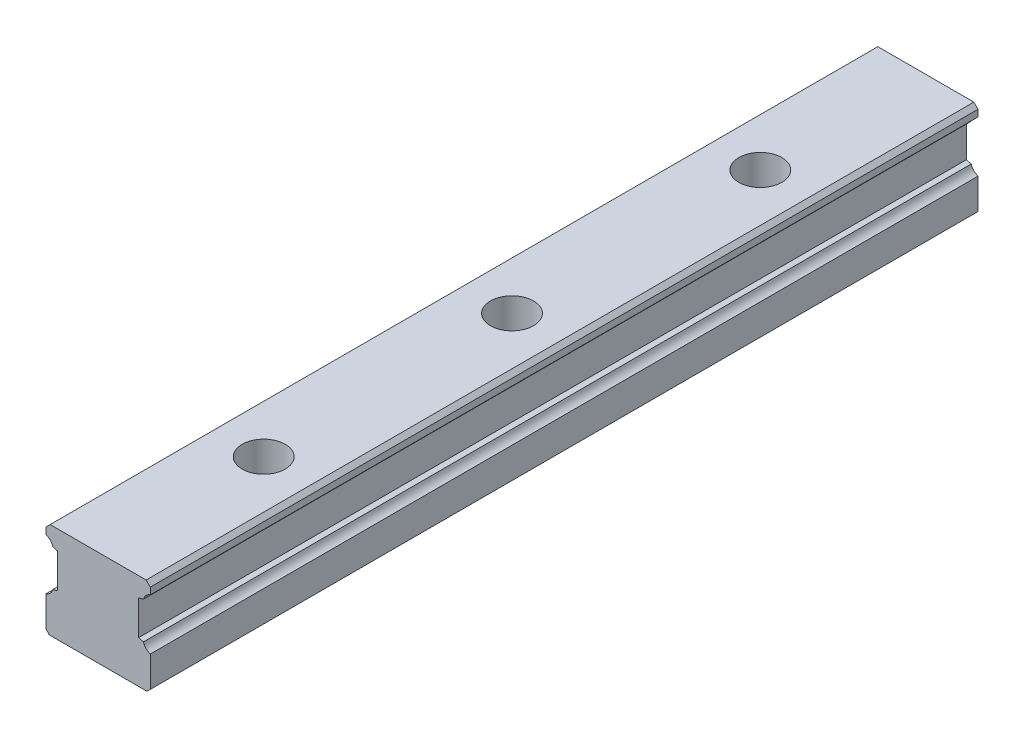
from build123d import *

# Parameters (mm, degrees)
RESSALTO_EXTRUS_O1_DEPTH                             = 500
REBAIXO_PARA_PARAFUSO_DE_CABE_A_SEXTAVAD_D           = 18
REBAIXO_PARA_PARAFUSO_DE_CABE_A_SEXTAVAD_DEPTH       = 58
REBAIXO_PARA_PARAFUSO_DE_CABE_A_SEXTAVAD_CBORE_D     = 26
REBAIXO_PARA_PARAFUSO_DE_CABE_A_SEXTAVAD_CBORE_DEPTH = 25
CHANFRO1_SIZE2                                       = 2.500287455
CHANFRO1_SIZE                                        = 2.500257245
CHANFRO2_SIZE2                                       = 2.500423779
CHANFRO2_SIZE                                        = 2.500287455
CHANFRO3_SIZE                                        = 2


with BuildPart() as part:
    # Esboço1 → Ressalto-extrusão1 (new body)
    with BuildSketch(Plane.XY):
        with BuildLine():
            Line((-31.5, 20.527298986), (-31.5, 0))
            Line((-31.5, 0), (31.5, 0))
            Line((31.5, 0), (31.5, 20.527298986))
            ThreePointArc((31.5, 20.527298986), (28.900076881, 22.150342104), (27.397266061, 24.82156445))
            Line((27.397266061, 24.82156445), (24.5, 25.597882749))
            Line((24.5, 25.597882749), (24.5, 46.397686197))
            Line((24.5, 46.397686197), (27.397119712, 47.17387922))
            ThreePointArc((27.397119712, 47.17387922), (28.898613337, 49.848990738), (31.5, 51.474872705))
            Line((31.5, 51.474872705), (31.5, 58))
            Line((31.5, 58), (-31.5, 58))
            Line((-31.5, 58), (-31.5, 51.474872705))
            ThreePointArc((-31.5, 51.474872705), (-28.899411057, 49.849685923), (-27.397802135, 47.175837466))
            Line((-27.397802135, 47.175837466), (-24.5, 46.399706372))
            Line((-24.5, 46.399706372), (-24.5, 25.596973237))
            Line((-24.5, 25.596973237), (-27.397939574, 24.823365186))
            ThreePointArc((-27.397939574, 24.823365186), (-28.900095464, 22.151244343), (-31.5, 20.527298986))
        make_face()
    extrude(amount=RESSALTO_EXTRUS_O1_DEPTH)

    # Rebaixo para parafuso de cabeça sextavada de M161
    with Locations(Plane(origin=(0, 58, 0), x_dir=(1, 0, 0), z_dir=(0, 1, 0))):
        with Locations((0, -100), (0, -250), (0, -400), (0, -550), (0, -700), (0, -850), (0, -1000), (0, -1150), (0, -1300), (0, -1450), (0, -1600), (0, -1750), (0, -1900), (0, -2050), (0, -2200), (0, -2350)):
            CounterBoreHole(REBAIXO_PARA_PARAFUSO_DE_CABE_A_SEXTAVAD_D / 2, REBAIXO_PARA_PARAFUSO_DE_CABE_A_SEXTAVAD_CBORE_D / 2, REBAIXO_PARA_PARAFUSO_DE_CABE_A_SEXTAVAD_CBORE_DEPTH, depth=REBAIXO_PARA_PARAFUSO_DE_CABE_A_SEXTAVAD_DEPTH)

    # Chanfro1
    chanfro1_edges = [part.edges().sort_by_distance(p)[0] for p in [
        (-31.5, 58, 250),
    ]]
    chamfer(chanfro1_edges, length=CHANFRO1_SIZE, length2=CHANFRO1_SIZE2)

    # Chanfro2
    chanfro2_edges = [part.edges().sort_by_distance(p)[0] for p in [
        (31.5, 58, 250),
    ]]
    chamfer(chanfro2_edges, length=CHANFRO2_SIZE, length2=CHANFRO2_SIZE2)

    # Chanfro3
    chanfro3_edges = [part.edges().sort_by_distance(p)[0] for p in [
        (31.5, 0, 250),
        (-31.5, 0, 250),
    ]]
    chamfer(chanfro3_edges, length=CHANFRO3_SIZE)


solid = part.part
